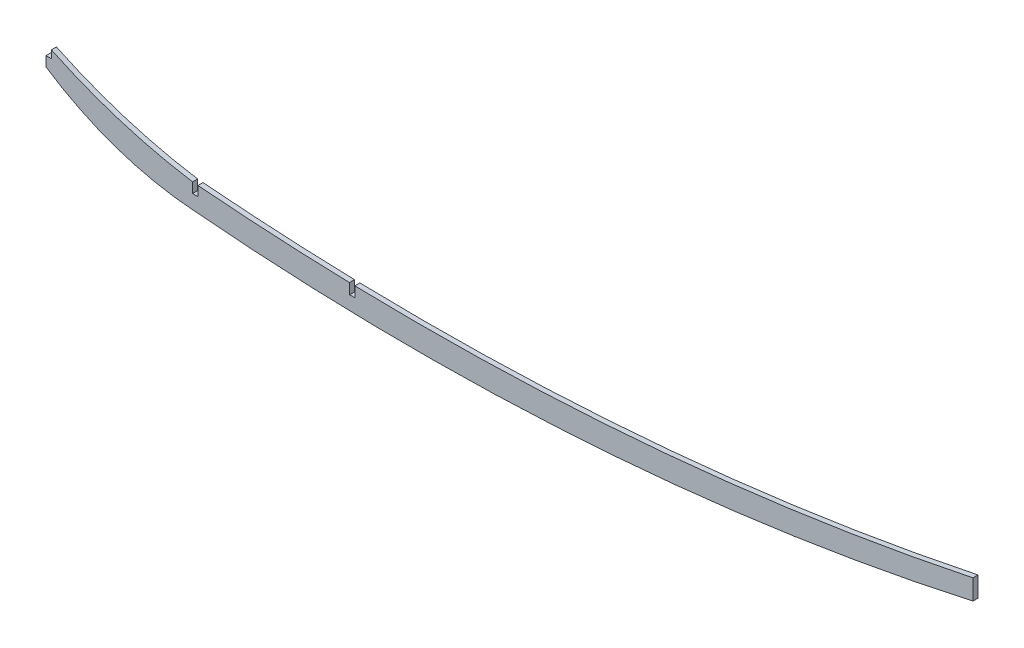
from build123d import *

# Parameters (mm, degrees)
BOSS_EXTRUDE1_DEPTH = 1.5875
SKETCH2_W           = 3.3782
SKETCH2_H           = 6.477
SKETCH2_H_2         = 12.7
CUT_EXTRUDE1_DEPTH  = 4.175


with BuildPart() as part:
    # Sketch1 → Boss-Extrude1 (new body, symmetric)
    with BuildSketch(Plane.XY):
        with BuildLine():
            Line((0, -97.563004684), (0, -84.863004684))
            ThreePointArc((0, -84.863004684), (45.091480007, -102.953300884), (92.3925, -114.048970912))
            ThreePointArc((92.3925, -114.048970912), (339.042339878, -117.088496575), (583.522463964, -84.303573898))
            Line((583.522463964, -84.303573898), (583.522463964, -97.003573898))
            ThreePointArc((583.522463964, -97.003573898), (339.198389145, -132.023125314), (92.3925, -129.288970912))
            ThreePointArc((92.3925, -129.288970912), (44.158404147, -119.360611557), (0, -97.563004684))
        make_face()
    extrude(amount=BOSS_EXTRUDE1_DEPTH, both=True)

    # Sketch2 → Cut-Extrude1 (cut, through all)
    with BuildSketch(Plane.XY.offset(1.5875)):
        with Locations((1.6891, -88.101504684)):
            Rectangle(SKETCH2_W, SKETCH2_H)
        with Locations((93.98, -114.06579143)):
            Rectangle(SKETCH2_W, SKETCH2_H_2)
        Polygon((191.155368795, -126.195526401), (194.532828758, -126.124819669), (194.267013976, -113.427601765), (190.889554014, -113.498308497), align=None)
    extrude(amount=-CUT_EXTRUDE1_DEPTH, mode=Mode.SUBTRACT)


solid = part.part
